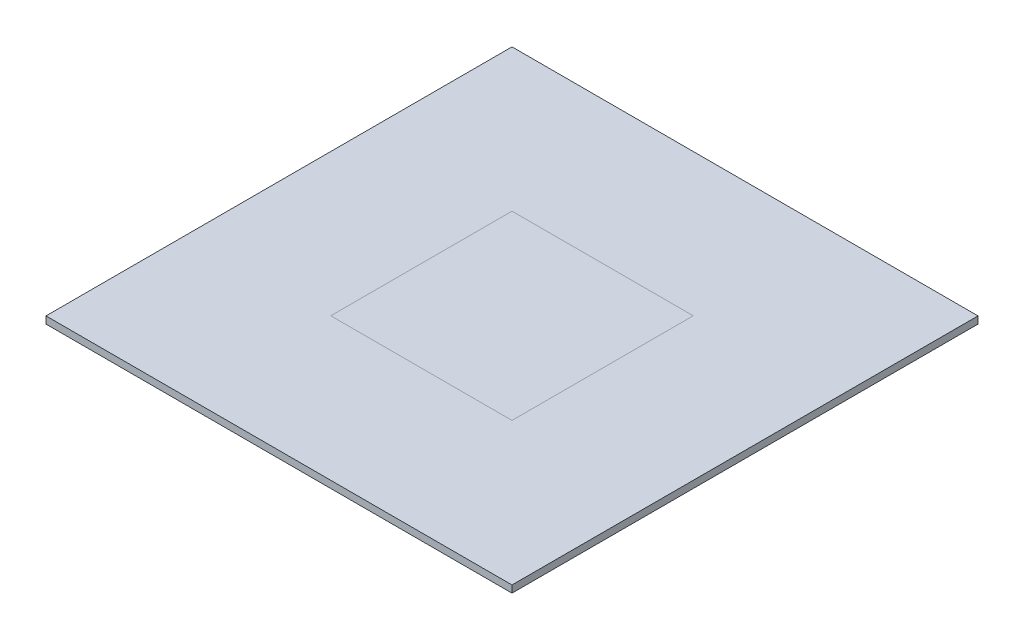
from build123d import *

# Parameters (mm, degrees)
SKETCH1_W           = 90
SKETCH1_H           = 90
BOSS_EXTRUDE1_DEPTH = 1.375


with BuildPart() as part:
    # Sketch1 → Boss-Extrude1 (new body)
    with BuildSketch(Plane(origin=(0, 0, 0), x_dir=(1, 0, 0), z_dir=(0, 1, 0))):
        Rectangle(SKETCH1_W, SKETCH1_H)
    extrude(amount=BOSS_EXTRUDE1_DEPTH)


solid = part.part
